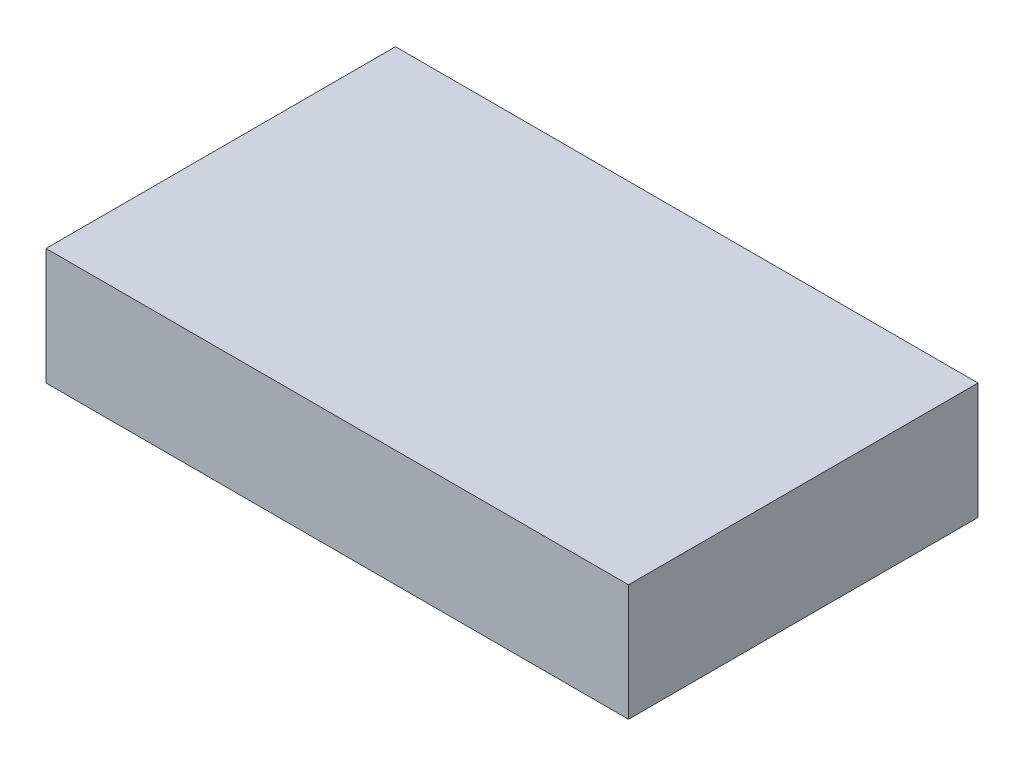
from build123d import *

# Parameters (mm, degrees)
SKETCH1_W           = 95.25
SKETCH1_H           = 19.05
BOSS_EXTRUDE1_DEPTH = 57.15


with BuildPart() as part:
    # Sketch1 → Boss-Extrude1 (new body)
    with BuildSketch(Plane.XY):
        with Locations((47.625, 9.525)):
            Rectangle(SKETCH1_W, SKETCH1_H)
    extrude(amount=BOSS_EXTRUDE1_DEPTH)


solid = part.part
